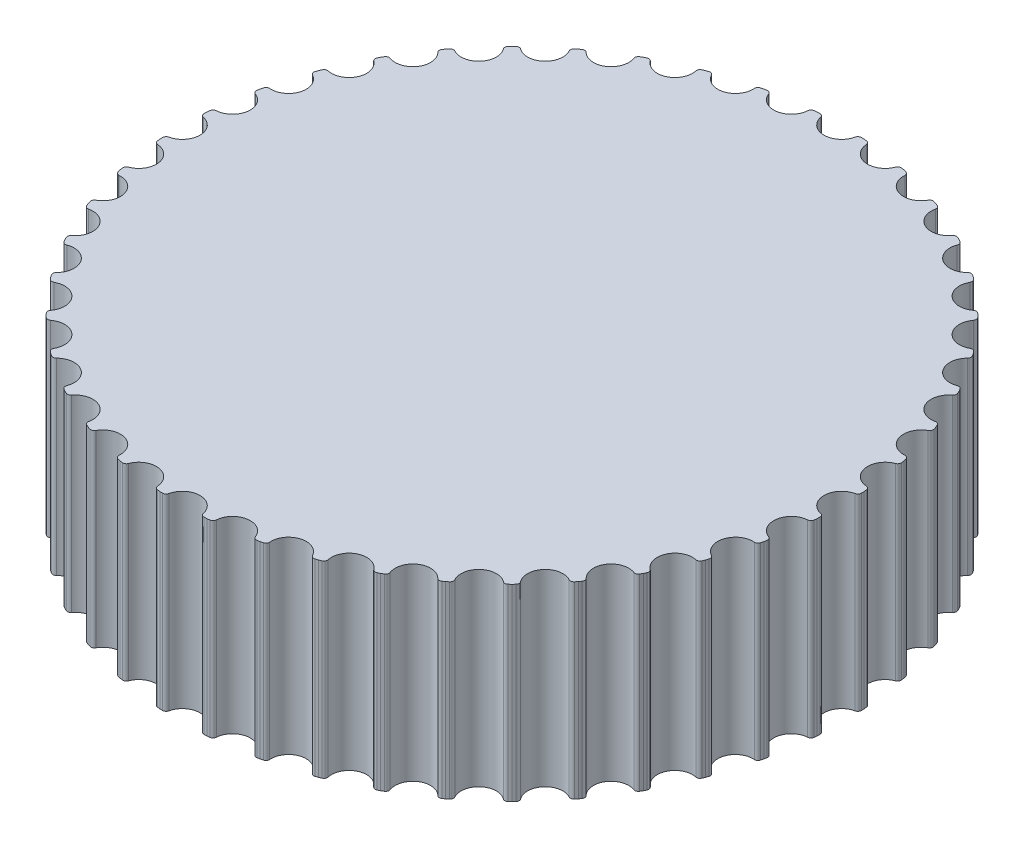
from build123d import *

# Parameters (mm, degrees)
SKETCH1_R           = 14.015
BOSS_EXTRUDE1_DEPTH = 8
CUT_EXTRUDE1_DEPTH  = 9
CIRPATTERN1_COUNT   = 44


with BuildPart() as part:
    # Sketch1 → Boss-Extrude1 (new body)
    with BuildSketch(Plane(origin=(0, 0, 0), x_dir=(1, 0, 0), z_dir=(0, 1, 0))):
        Circle(SKETCH1_R)
    extrude(amount=BOSS_EXTRUDE1_DEPTH)

    # Sketch2 → Cut-Extrude1 (cut, through all)
    with BuildSketch(Plane(origin=(0, 8, 0), x_dir=(1, 0, 0), z_dir=(0, 1, 0))):
        with BuildLine():
            Line((-0.879281525, 13.968), (-1, 13.968))
            Line((-1, 13.968), (-1, 14.164537955))
            Line((-1, 14.164537955), (1, 14.164537955))
            Line((1, 14.164537955), (1, 13.968))
            Line((1, 13.968), (0.879281525, 13.968))
            ThreePointArc((0.879281525, 13.968), (0.785207086, 13.934833214), (0.732734604, 13.85))
            ThreePointArc((0.732734604, 13.85), (0, 13.26), (-0.732734604, 13.85))
            ThreePointArc((-0.732734604, 13.85), (-0.785207086, 13.934833214), (-0.879281525, 13.968))
        make_face()
    cut_extrude1 = extrude(amount=-CUT_EXTRUDE1_DEPTH, mode=Mode.SUBTRACT)

    # CirPattern1: Cut-Extrude1 ×44 about axis
    cirpattern1_axis = Axis((0, 0, 0), (0, 1, 0))
    for i in range(1, CIRPATTERN1_COUNT):
        add(cut_extrude1.rotate(cirpattern1_axis, i * 360 / CIRPATTERN1_COUNT), mode=Mode.SUBTRACT)


solid = part.part
